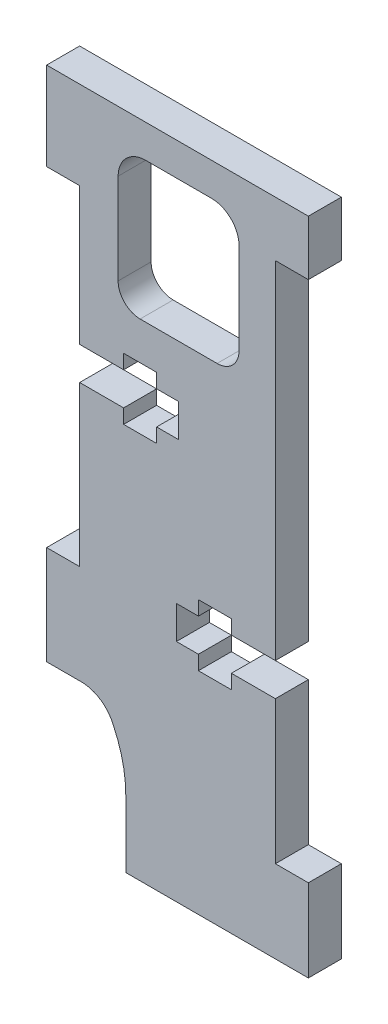
from build123d import *

# Parameters (mm, degrees)
BOSS_EXTRUDE1_DEPTH = 3


with BuildPart() as part:
    # Model → Boss-Extrude1 (new body)
    with BuildSketch(Plane.XY):
        with BuildLine():
            Line((37.008, 72.936), (25.508, 72.936))
            Line((25.508, 72.936), (25.508, 64.936))
            Line((25.508, 64.936), (28.508, 64.936))
            Line((28.508, 64.936), (28.508, 52.436))
            Line((28.508, 52.436), (32.508, 52.436))
            Line((32.508, 52.436), (32.508, 53.736))
            Line((32.508, 53.736), (35.508, 53.736))
            Line((35.508, 53.736), (35.508, 52.436))
            Line((35.508, 52.436), (37.508, 52.436))
            Line((37.508, 52.436), (37.508, 49.436))
            Line((37.508, 49.436), (35.508, 49.436))
            Line((35.508, 49.436), (35.508, 48.136))
            Line((35.508, 48.136), (32.508, 48.136))
            Line((32.508, 48.136), (32.508, 49.436))
            Line((32.508, 49.436), (28.508, 49.436))
            Line((28.508, 49.436), (28.508, 34.936))
            Line((28.508, 34.936), (25.508, 34.936))
            Line((25.508, 34.936), (25.508, 30.436))
            Line((25.508, 30.436), (25.508, 25.936))
            Line((25.508, 25.936), (28.7315, 25.936))
            ThreePointArc((28.7315, 25.936), (30.43997083, 25.380193402), (31.569029282, 23.982688281))
            ThreePointArc((31.569029282, 23.982688281), (32.427770148, 21.524625278), (32.708, 18.936))
            Line((32.708, 18.936), (32.708, 12.936))
            Line((32.708, 12.936), (49.308, 12.936))
            Line((49.308, 12.936), (49.308, 20.436))
            Line((49.308, 20.436), (46.308, 20.436))
            Line((46.308, 20.436), (46.308, 33.436))
            Line((46.308, 33.436), (42.308, 33.436))
            Line((42.308, 33.436), (42.308, 32.136))
            Line((42.308, 32.136), (39.308, 32.136))
            Line((39.308, 32.136), (39.308, 33.436))
            Line((39.308, 33.436), (37.308, 33.436))
            Line((37.308, 33.436), (37.308, 36.436))
            Line((37.308, 36.436), (39.308, 36.436))
            Line((39.308, 36.436), (39.308, 37.736))
            Line((39.308, 37.736), (42.308, 37.736))
            Line((42.308, 37.736), (42.308, 36.436))
            Line((42.308, 36.436), (46.308, 36.436))
            Line((46.308, 36.436), (46.308, 67.936))
            Line((46.308, 67.936), (49.308, 67.936))
            Line((49.308, 67.936), (49.308, 72.936))
            Line((49.308, 72.936), (37.008, 72.936))
        make_face()
        with BuildLine():
            Line((41.008, 57.1861), (34.008, 57.1861))
            ThreePointArc((34.008, 57.1861), (32.593735358, 57.771764643), (32.008, 59.186))
            Line((32.008, 59.186), (32.008, 67.436))
            ThreePointArc((32.008, 67.436), (32.7402, 69.2038), (34.508, 69.936))
            Line((34.508, 69.936), (40.508, 69.936))
            ThreePointArc((40.508, 69.936), (42.27578125, 69.20378125), (43.008, 67.436))
            Line((43.008, 67.436), (43.008, 59.186))
            ThreePointArc((43.008, 59.186), (42.422214645, 57.771814644), (41.008, 57.1861))
        make_face(mode=Mode.SUBTRACT)
    extrude(amount=BOSS_EXTRUDE1_DEPTH)


solid = part.part
